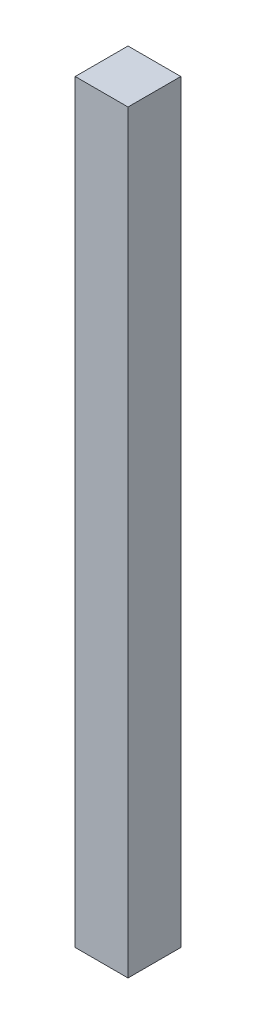
from build123d import *

# Parameters (mm, degrees)
SKETCH1_W           = 4.9
SKETCH1_H           = 4.9
BOSS_EXTRUDE1_DEPTH = 70


with BuildPart() as part:
    # Sketch1 → Boss-Extrude1 (new body)
    with BuildSketch(Plane(origin=(0, 0, 0), x_dir=(1, 0, 0), z_dir=(0, 1, 0))):
        with Locations((2.45, 2.45)):
            Rectangle(SKETCH1_W, SKETCH1_H)
    extrude(amount=BOSS_EXTRUDE1_DEPTH)


solid = part.part
